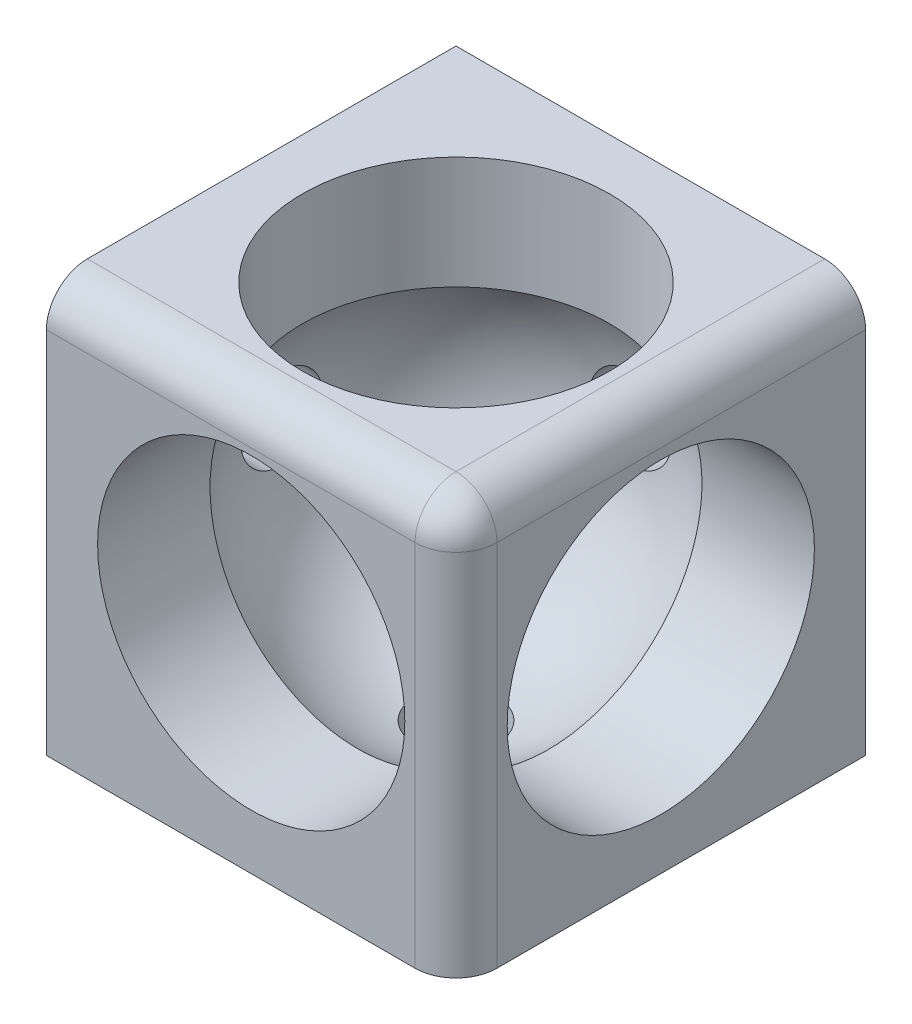
from build123d import *

# Parameters (mm, degrees)
SKETCH1_W           = 40
SKETCH1_H           = 40
BOSS_EXTRUDE1_DEPTH = 20
FILLET1_R           = 4
SKETCH12_R          = 15
CUT_EXTRUDE2_DEPTH  = 20
SKETCH13_R          = 15
CUT_EXTRUDE3_DEPTH  = 20
SKETCH14_R          = 15
CUT_EXTRUDE4_DEPTH  = 20
SKETCH15_R          = 4
CUT_EXTRUDE5_DEPTH  = 20
SKETCH16_R          = 4
CUT_EXTRUDE6_DEPTH  = 20
SKETCH17_R          = 4
CUT_EXTRUDE7_DEPTH  = 20


with BuildPart() as part:
    # Sketch1 → Boss-Extrude1 (new body, symmetric)
    with BuildSketch(Plane(origin=(0, 0, 0), x_dir=(1, 0, 0), z_dir=(0, 1, 0))):
        Rectangle(SKETCH1_W, SKETCH1_H)
    extrude(amount=BOSS_EXTRUDE1_DEPTH, both=True)

    # Fillet1
    fillet1_edges = [part.edges().sort_by_distance(p)[0] for p in [
        (20, 20, 0),
        (20, 0, 20),
        (0, 20, 20),
    ]]
    fillet(fillet1_edges, radius=FILLET1_R)

    # Sketch2 → Cut-Revolve1 (revolve, cut)
    with BuildSketch(Plane(origin=(0, 0, 0), x_dir=(1, 0, 0), z_dir=(0, 1, 0))):
        with BuildLine():
            Line((0, 17.5), (0, -17.5))
            ThreePointArc((0, -17.5), (-17.5, 0), (0, 17.5))
        make_face()
    revolve(axis=Axis((0, 0, -20.989422068), (0, 0, 1)), mode=Mode.SUBTRACT)

    # Sketch12 → Cut-Extrude2 (cut)
    with BuildSketch(Plane(origin=(0, 20, 0), x_dir=(1, 0, 0), z_dir=(0, 1, 0))):
        Circle(SKETCH12_R)
    extrude(amount=-CUT_EXTRUDE2_DEPTH, mode=Mode.SUBTRACT)

    # Sketch13 → Cut-Extrude3 (cut)
    with BuildSketch(Plane(origin=(20, 0, 0), x_dir=(0, 0, -1), z_dir=(1, 0, 0))):
        Circle(SKETCH13_R)
    extrude(amount=-CUT_EXTRUDE3_DEPTH, mode=Mode.SUBTRACT)

    # Sketch14 → Cut-Extrude4 (cut)
    with BuildSketch(Plane.XY.offset(20)):
        with Locations((0, 0.367598837)):
            Circle(SKETCH14_R)
    extrude(amount=-CUT_EXTRUDE4_DEPTH, mode=Mode.SUBTRACT)

    # Sketch15 → Cut-Extrude5 (cut)
    with BuildSketch(Plane(origin=(0, 0, -20), x_dir=(-1, 0, 0), z_dir=(0, 0, -1))):
        Circle(SKETCH15_R)
    extrude(amount=-CUT_EXTRUDE5_DEPTH, mode=Mode.SUBTRACT)

    # Sketch16 → Cut-Extrude6 (cut)
    with BuildSketch(Plane.XZ.offset(20)):
        Circle(SKETCH16_R)
    extrude(amount=-CUT_EXTRUDE6_DEPTH, mode=Mode.SUBTRACT)

    # Sketch17 → Cut-Extrude7 (cut)
    with BuildSketch(Plane.ZY.offset(20)):
        Circle(SKETCH17_R)
    extrude(amount=-CUT_EXTRUDE7_DEPTH, mode=Mode.SUBTRACT)


solid = part.part
